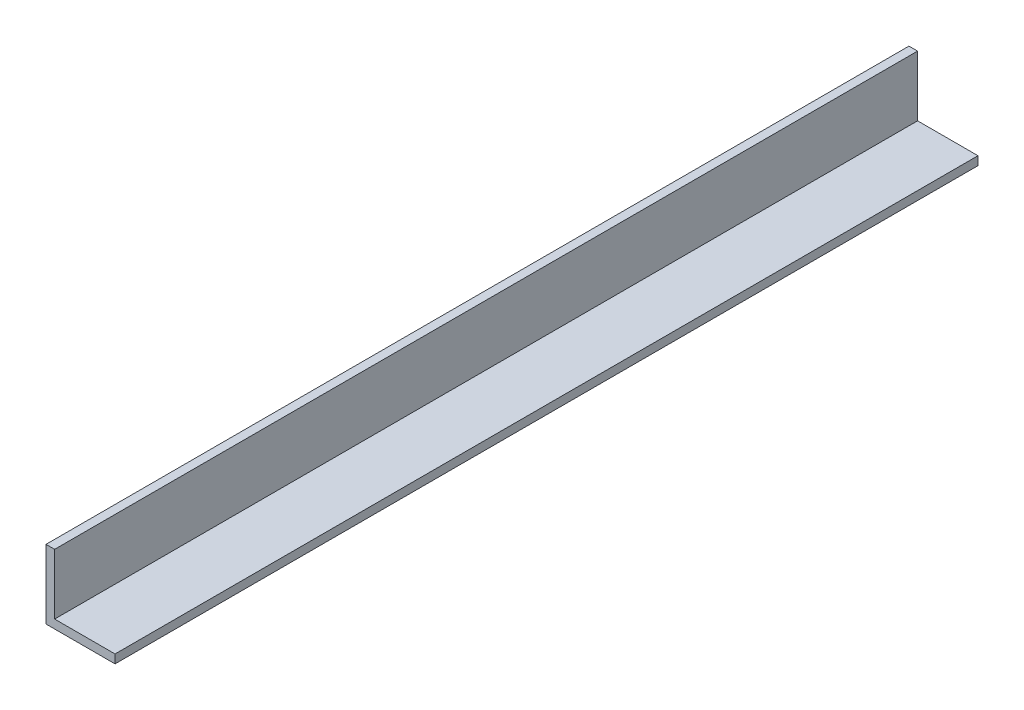
from build123d import *

# Parameters (mm, degrees)
BOSS_EXTRUDE1_DEPTH = 317.5


with BuildPart() as part:
    # Sketch1 → Boss-Extrude1 (new body)
    with BuildSketch(Plane.XY):
        Polygon((0, 0), (25.4, 0), (25.4, 3.175), (3.175, 3.175), (3.175, 25.4), (0, 25.4), align=None)
    extrude(amount=BOSS_EXTRUDE1_DEPTH)


solid = part.part
